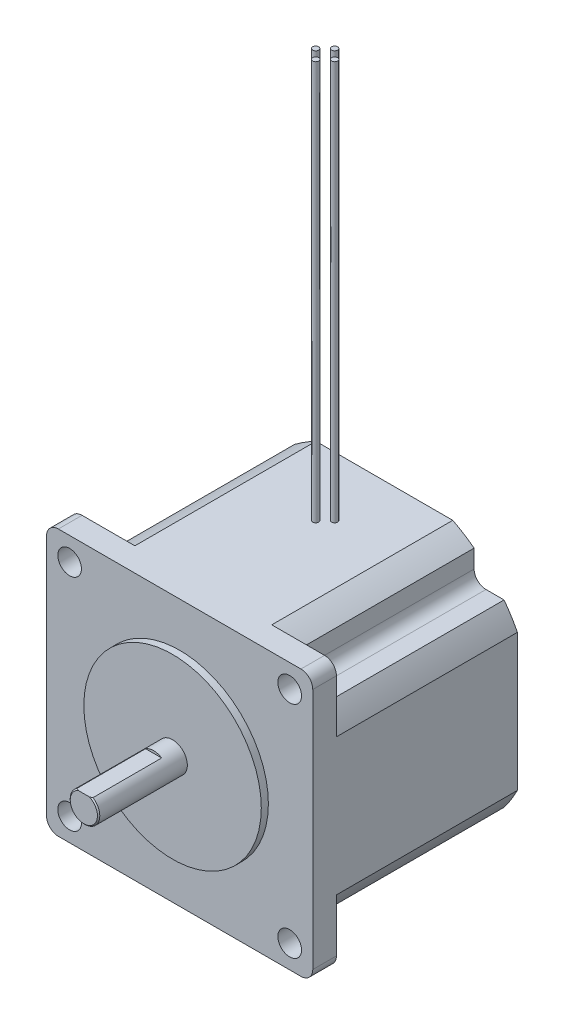
from build123d import *

# Parameters (mm, degrees)
SKETCH1_W           = 57.15
SKETCH1_H           = 57.15
BOSS_EXTRUDE1_DEPTH = 43.942
CUT_EXTRUDE1_DEPTH  = 38.862
CUT_EXTRUDE2_DEPTH  = 38.862
CUT_EXTRUDE3_DEPTH  = 38.862
CUT_EXTRUDE4_DEPTH  = 38.862
CUT_EXTRUDE5_DEPTH  = 38.862
CUT_EXTRUDE6_DEPTH  = 38.862
CUT_EXTRUDE7_DEPTH  = 38.862
CUT_EXTRUDE8_DEPTH  = 38.862
SKETCH10_R          = 19.05
BOSS_EXTRUDE2_DEPTH = 1.524
SKETCH11_R          = 3.175
BOSS_EXTRUDE3_DEPTH = 19.05
CUT_EXTRUDE9_DEPTH  = 14.986
SKETCH13_W          = 0.635
SKETCH13_H          = 85.725
SKETCH14_W          = 0.635
SKETCH14_H          = 85.725
SKETCH15_W          = 0.635
SKETCH15_H          = 85.725
SKETCH16_W          = 0.635
SKETCH16_H          = 85.725
HOLE1_D             = 5.08
HOLE1_DEPTH         = 25.654
HOLE2_D             = 5.08
HOLE2_DEPTH         = 25.654
HOLE3_D             = 5.08
HOLE3_DEPTH         = 25.654
HOLE4_D             = 5.08
HOLE4_DEPTH         = 25.654
CHAMFER1_SIZE       = 0.254
FILLET1_R           = 2.54
FILLET2_R           = 2.54
FILLET3_R           = 2.54
FILLET4_R           = 2.54
FILLET5_R           = 2.54
FILLET6_R           = 2.54
FILLET7_R           = 2.54
FILLET8_R           = 2.54


with BuildPart() as part:
    # Sketch1 → Boss-Extrude1 (new body)
    with BuildSketch(Plane.XY.offset(43.942)):
        Rectangle(SKETCH1_W, SKETCH1_H)
    extrude(amount=-BOSS_EXTRUDE1_DEPTH)

    # Sketch2 → Cut-Extrude1 (cut)
    with BuildSketch(Plane(origin=(0, 0, 0), x_dir=(-1, 0, 0), z_dir=(0, 0, -1))):
        with BuildLine():
            Line((-28.575, -28.575), (-14.692533342, -28.575))
            ThreePointArc((-14.692533342, -28.575), (-22.720047986, -22.720047986), (-28.575, -14.692533342))
            Line((-28.575, -14.692533342), (-28.575, -28.575))
        make_face()
    extrude(amount=-CUT_EXTRUDE1_DEPTH, mode=Mode.SUBTRACT)

    # Sketch3 → Cut-Extrude2 (cut)
    with BuildSketch(Plane(origin=(0, 0, 0), x_dir=(-1, 0, 0), z_dir=(0, 0, -1))):
        with BuildLine():
            Line((-19.2786, -25.7048), (-19.2786, -19.2786))
            Line((-19.2786, -19.2786), (-25.7048, -19.2786))
            ThreePointArc((-25.7048, -19.2786), (-22.720047986, -22.720047986), (-19.2786, -25.7048))
        make_face()
    extrude(amount=-CUT_EXTRUDE2_DEPTH, mode=Mode.SUBTRACT)

    # Sketch4 → Cut-Extrude3 (cut)
    with BuildSketch(Plane(origin=(0, 0, 0), x_dir=(-1, 0, 0), z_dir=(0, 0, -1))):
        with BuildLine():
            Line((-28.575, 28.575), (-28.575, 14.692533342))
            ThreePointArc((-28.575, 14.692533342), (-22.720047986, 22.720047986), (-14.692533342, 28.575))
            Line((-14.692533342, 28.575), (-28.575, 28.575))
        make_face()
    extrude(amount=-CUT_EXTRUDE3_DEPTH, mode=Mode.SUBTRACT)

    # Sketch5 → Cut-Extrude4 (cut)
    with BuildSketch(Plane(origin=(0, 0, 0), x_dir=(-1, 0, 0), z_dir=(0, 0, -1))):
        with BuildLine():
            Line((-25.7048, 19.2786), (-19.2786, 19.2786))
            Line((-19.2786, 19.2786), (-19.2786, 25.7048))
            ThreePointArc((-19.2786, 25.7048), (-22.720047986, 22.720047986), (-25.7048, 19.2786))
        make_face()
    extrude(amount=-CUT_EXTRUDE4_DEPTH, mode=Mode.SUBTRACT)

    # Sketch6 → Cut-Extrude5 (cut)
    with BuildSketch(Plane(origin=(0, 0, 0), x_dir=(-1, 0, 0), z_dir=(0, 0, -1))):
        with BuildLine():
            Line((28.575, 28.575), (14.692533342, 28.575))
            ThreePointArc((14.692533342, 28.575), (22.720047986, 22.720047986), (28.575, 14.692533342))
            Line((28.575, 14.692533342), (28.575, 28.575))
        make_face()
    extrude(amount=-CUT_EXTRUDE5_DEPTH, mode=Mode.SUBTRACT)

    # Sketch7 → Cut-Extrude6 (cut)
    with BuildSketch(Plane(origin=(0, 0, 0), x_dir=(-1, 0, 0), z_dir=(0, 0, -1))):
        with BuildLine():
            Line((19.2786, 25.7048), (19.2786, 19.2786))
            Line((19.2786, 19.2786), (25.7048, 19.2786))
            ThreePointArc((25.7048, 19.2786), (22.720047986, 22.720047986), (19.2786, 25.7048))
        make_face()
    extrude(amount=-CUT_EXTRUDE6_DEPTH, mode=Mode.SUBTRACT)

    # Sketch8 → Cut-Extrude7 (cut)
    with BuildSketch(Plane(origin=(0, 0, 0), x_dir=(-1, 0, 0), z_dir=(0, 0, -1))):
        with BuildLine():
            Line((28.575, -28.575), (28.575, -14.692533342))
            ThreePointArc((28.575, -14.692533342), (22.720047986, -22.720047986), (14.692533342, -28.575))
            Line((14.692533342, -28.575), (28.575, -28.575))
        make_face()
    extrude(amount=-CUT_EXTRUDE7_DEPTH, mode=Mode.SUBTRACT)

    # Sketch9 → Cut-Extrude8 (cut)
    with BuildSketch(Plane(origin=(0, 0, 0), x_dir=(-1, 0, 0), z_dir=(0, 0, -1))):
        with BuildLine():
            Line((25.7048, -19.2786), (19.2786, -19.2786))
            Line((19.2786, -19.2786), (19.2786, -25.7048))
            ThreePointArc((19.2786, -25.7048), (22.720047986, -22.720047986), (25.7048, -19.2786))
        make_face()
    extrude(amount=-CUT_EXTRUDE8_DEPTH, mode=Mode.SUBTRACT)

    # Sketch10 → Boss-Extrude2 (add)
    with BuildSketch(Plane.XY.offset(43.942)):
        Circle(SKETCH10_R)
    extrude(amount=BOSS_EXTRUDE2_DEPTH)

    # Sketch11 → Boss-Extrude3 (add)
    with BuildSketch(Plane.XY.offset(45.466)):
        Circle(SKETCH11_R)
    extrude(amount=BOSS_EXTRUDE3_DEPTH)

    # Sketch12 → Cut-Extrude9 (cut)
    with BuildSketch(Plane.XY.offset(64.516)):
        with BuildLine():
            Line((-1.722711816, 2.667), (1.722711816, 2.667))
            ThreePointArc((1.722711816, 2.667), (0, 3.175), (-1.722711816, 2.667))
        make_face()
    extrude(amount=-CUT_EXTRUDE9_DEPTH, mode=Mode.SUBTRACT)

    # Sketch13 → Revolve1 (revolve)
    with BuildSketch(Plane(origin=(0, 0, 12.7), x_dir=(-1, 0, 0), z_dir=(0, 0, -1))):
        with Locations((1.7145, 71.4375)):
            Rectangle(SKETCH13_W, SKETCH13_H)
    revolve(axis=Axis((-2.032, 28.575, 12.7), (0, 1, 0)))

    # Sketch14 → Revolve2 (revolve)
    with BuildSketch(Plane(origin=(0, 0, 12.7), x_dir=(-1, 0, 0), z_dir=(0, 0, -1))):
        with Locations((-2.3495, 71.4375)):
            Rectangle(SKETCH14_W, SKETCH14_H)
    revolve(axis=Axis((2.032, 28.575, 12.7), (0, 1, 0)))

    # Sketch15 → Revolve3 (revolve)
    with BuildSketch(Plane(origin=(0, 0, 14.732), x_dir=(-1, 0, 0), z_dir=(0, 0, -1))):
        with Locations((-0.3175, 71.4375)):
            Rectangle(SKETCH15_W, SKETCH15_H)
    revolve(axis=Axis((0, 28.575, 14.732), (0, 1, 0)))

    # Sketch16 → Revolve4 (revolve)
    with BuildSketch(Plane(origin=(0, 0, 10.668), x_dir=(-1, 0, 0), z_dir=(0, 0, -1))):
        with Locations((-0.3175, 71.4375)):
            Rectangle(SKETCH16_W, SKETCH16_H)
    revolve(axis=Axis((0, 28.575, 10.668), (0, 1, 0)))

    # Hole1
    with Locations(Plane(origin=(0, 0, 38.862), x_dir=(-1, 0, 0), z_dir=(0, 0, -1))):
        with Locations((23.622, -23.622)):
            Hole(HOLE1_D / 2, depth=HOLE1_DEPTH)

    # Hole2
    with Locations(Plane(origin=(0, 0, 38.862), x_dir=(-1, 0, 0), z_dir=(0, 0, -1))):
        with Locations((23.622, 23.622)):
            Hole(HOLE2_D / 2, depth=HOLE2_DEPTH)

    # Hole3
    with Locations(Plane(origin=(0, 0, 38.862), x_dir=(-1, 0, 0), z_dir=(0, 0, -1))):
        with Locations((-23.622, 23.622)):
            Hole(HOLE3_D / 2, depth=HOLE3_DEPTH)

    # Hole4
    with Locations(Plane(origin=(0, 0, 38.862), x_dir=(-1, 0, 0), z_dir=(0, 0, -1))):
        with Locations((-23.622, -23.622)):
            Hole(HOLE4_D / 2, depth=HOLE4_DEPTH)

    # Chamfer1
    chamfer1_edges = [part.edges().sort_by_distance(p)[0] for p in [
        (-1.51838977, -2.78838977, 64.516),
    ]]
    chamfer(chamfer1_edges, length=CHAMFER1_SIZE)

    # Fillet1
    fillet1_edges = [part.edges().sort_by_distance(p)[0] for p in [
        (-28.575, 28.575, 41.402),
    ]]
    fillet(fillet1_edges, radius=FILLET1_R)

    # Fillet2
    fillet2_edges = [part.edges().sort_by_distance(p)[0] for p in [
        (-28.575, -28.575, 41.402),
    ]]
    fillet(fillet2_edges, radius=FILLET2_R)

    # Fillet3
    fillet3_edges = [part.edges().sort_by_distance(p)[0] for p in [
        (28.575, 28.575, 41.402),
    ]]
    fillet(fillet3_edges, radius=FILLET3_R)

    # Fillet4
    fillet4_edges = [part.edges().sort_by_distance(p)[0] for p in [
        (-19.2786, 19.2786, 19.431),
    ]]
    fillet(fillet4_edges, radius=FILLET4_R)

    # Fillet5
    fillet5_edges = [part.edges().sort_by_distance(p)[0] for p in [
        (28.575, -28.575, 41.402),
    ]]
    fillet(fillet5_edges, radius=FILLET5_R)

    # Fillet6
    fillet6_edges = [part.edges().sort_by_distance(p)[0] for p in [
        (19.2786, -19.2786, 19.431),
    ]]
    fillet(fillet6_edges, radius=FILLET6_R)

    # Fillet7
    fillet7_edges = [part.edges().sort_by_distance(p)[0] for p in [
        (19.2786, 19.2786, 19.431),
    ]]
    fillet(fillet7_edges, radius=FILLET7_R)

    # Fillet8
    fillet8_edges = [part.edges().sort_by_distance(p)[0] for p in [
        (-19.2786, -19.2786, 19.431),
    ]]
    fillet(fillet8_edges, radius=FILLET8_R)


solid = part.part
